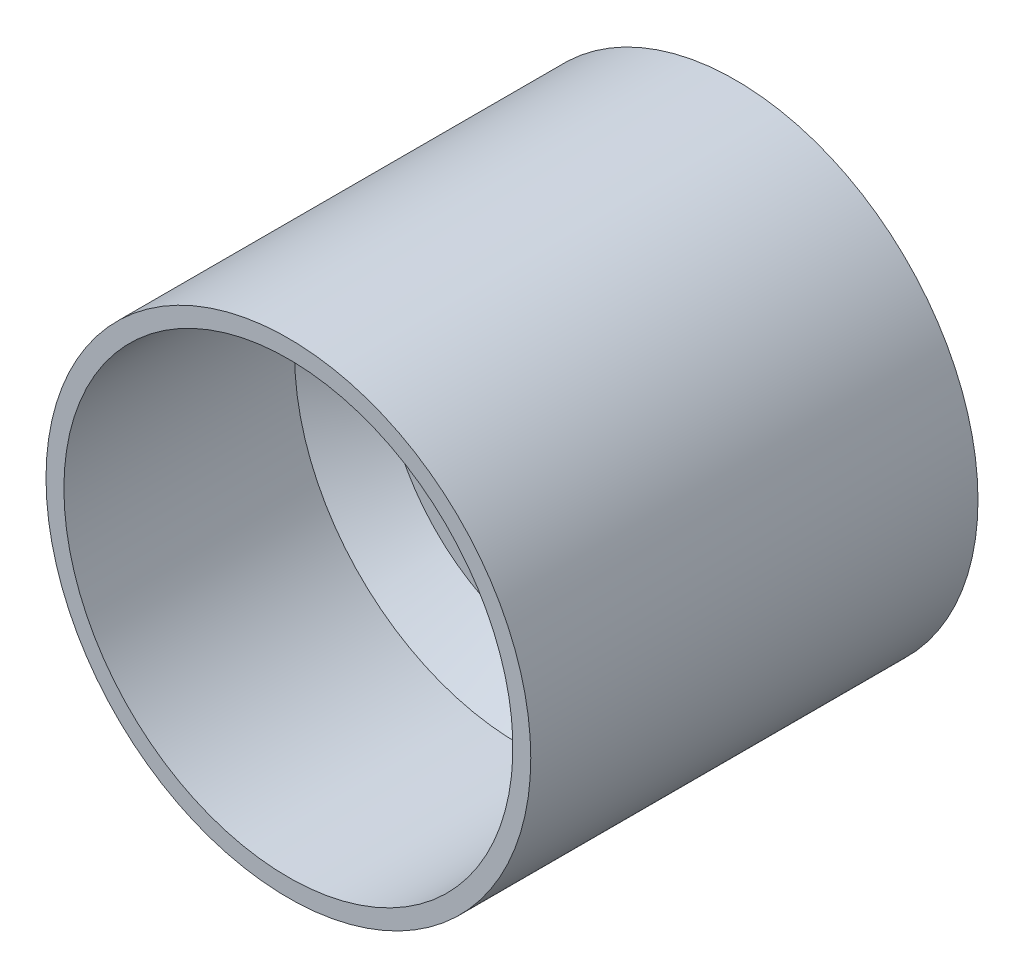
from build123d import *

# Parameters (mm, degrees)
SKETCH2_R          = 2
CUT_EXTRUDE1_DEPTH = 10
SKETCH3_W          = 25.1
SKETCH3_H          = 3
CHAMFER1_SIZE      = 5
SKETCH4_R          = 1.1
SKETCH4_R_2        = 1.5
CUT_EXTRUDE2_DEPTH = 10


with BuildPart() as part:
    # Sketch1 → Revolve1 (revolve)
    with BuildSketch(Plane(origin=(0, 0, 0), x_dir=(1, 0, 0), z_dir=(0, 1, 0))):
        Polygon((15.25, 26.5), (15.25, 23.5), (25.1, 23.5), (25.1, -23.5), (27.1, -23.5), (27.1, 26.5), align=None)
    revolve(axis=Axis((0, 0, -51.288157895), (0, 0, 1)))

    # Sketch2 → Cut-Extrude1 (cut)
    with BuildSketch(Plane(origin=(0, 0, -26.5), x_dir=(-1, 0, 0), z_dir=(0, 0, -1))):
        with Locations((0, 20.25)):
            Circle(SKETCH2_R)
        with Locations((17.537014427, -10.125)):
            Circle(SKETCH2_R)
        with Locations((-17.537014427, -10.125)):
            Circle(SKETCH2_R)
    extrude(amount=-CUT_EXTRUDE1_DEPTH, mode=Mode.SUBTRACT)

    # Sketch3 → Revolve2 (revolve)
    with BuildSketch(Plane(origin=(0, 0, 0), x_dir=(1, 0, 0), z_dir=(0, 1, 0))):
        with Locations((12.55, 8.8)):
            Rectangle(SKETCH3_W, SKETCH3_H)
    revolve(axis=Axis((0, 0, -51.288157895), (0, 0, 1)))

    # Chamfer1
    chamfer1_edges = [part.edges().sort_by_distance(p)[0] for p in [
        (-25.1, 0, -7.3),
        (-25.1, 0, -10.3),
    ]]
    chamfer(chamfer1_edges, length=CHAMFER1_SIZE)

    # Sketch4 → Cut-Extrude2 (cut)
    with BuildSketch(Plane(origin=(0, 0, -10.3), x_dir=(-1, 0, 0), z_dir=(0, 0, -1))):
        with Locations((-6.363961031, 6.363961031)):
            Circle(SKETCH4_R)
        with Locations((6.363961031, 6.363961031)):
            Circle(SKETCH4_R)
        with Locations((6.363961031, -6.363961031)):
            Circle(SKETCH4_R)
        with Locations((-6.363961031, -6.363961031)):
            Circle(SKETCH4_R)
        with Locations((0, 12.5)):
            Circle(SKETCH4_R_2)
        with Locations((0, -12.5)):
            Circle(SKETCH4_R_2)
        with BuildLine():
            Line((-6.05, 3.619392214), (-6.05, -3.619392214))
            ThreePointArc((-6.05, -3.619392214), (0, -7.05), (6.05, -3.619392214))
            Line((6.05, -3.619392214), (6.05, 3.619392214))
            ThreePointArc((6.05, 3.619392214), (0, 7.05), (-6.05, 3.619392214))
        make_face()
    extrude(amount=-CUT_EXTRUDE2_DEPTH, mode=Mode.SUBTRACT)


solid = part.part
